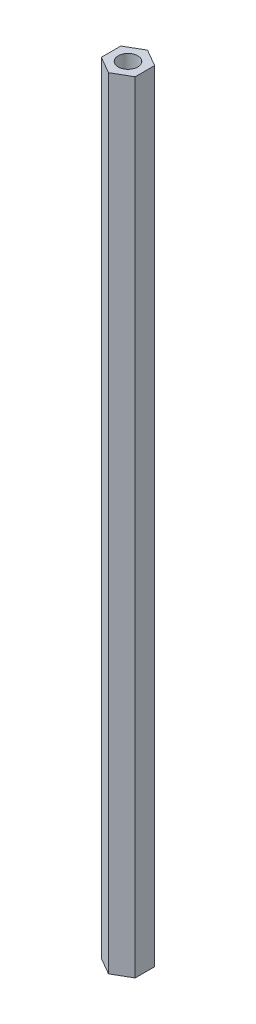
from build123d import *

# Parameters (mm, degrees)
ESQUISSE1_R      = 2.5
EXTRUSION1_DEPTH = 200


with BuildPart() as part:
    # Esquisse1 → Extrusion1 (new body)
    with BuildSketch(Plane(origin=(0, 0, 0), x_dir=(1, 0, 0), z_dir=(0, 1, 0))):
        Polygon((0, 5), (-4.330127019, 2.5), (-4.330127019, -2.5), (0, -5), (4.330127019, -2.5), (4.330127019, 2.5), align=None)
        Circle(ESQUISSE1_R, mode=Mode.SUBTRACT)
    extrude(amount=EXTRUSION1_DEPTH)


solid = part.part
